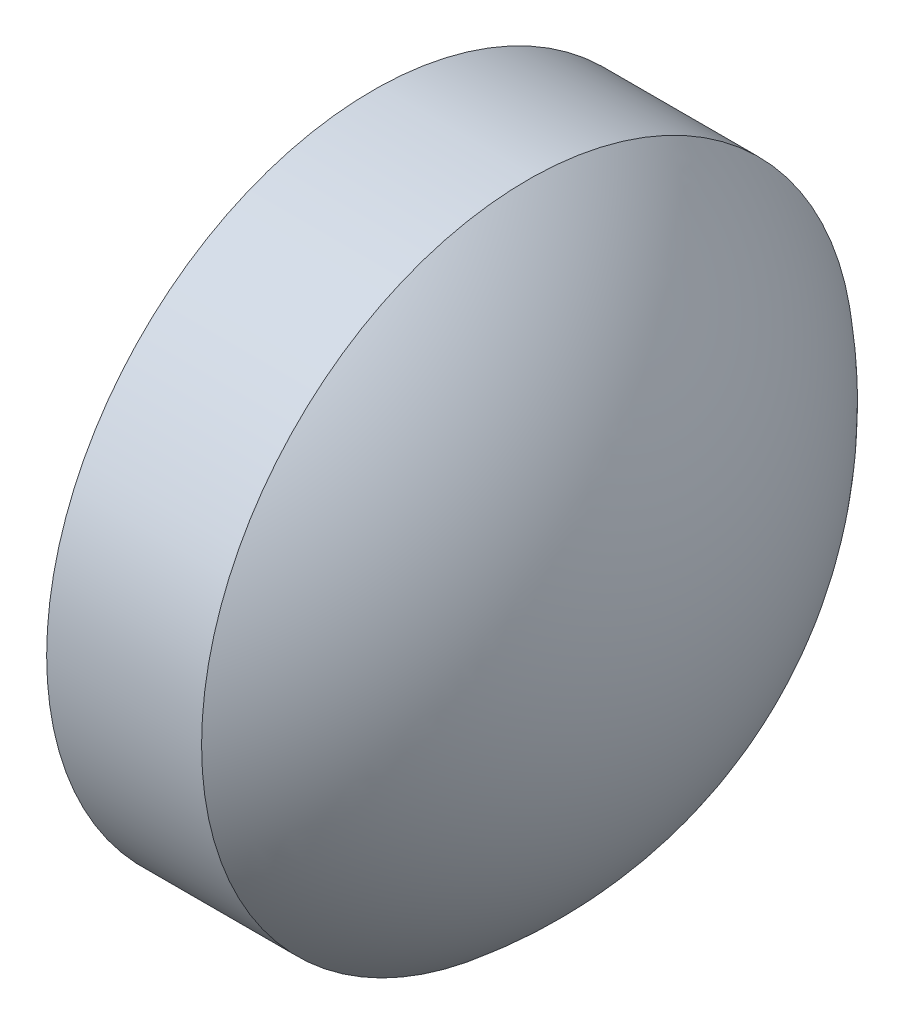
from build123d import *


with BuildPart() as part:
    # 草图1 → 旋转2 (revolve)
    with BuildSketch(Plane.XY, mode=Mode.PRIVATE) as revolve_2_sk:
        with BuildLine():
            Line((385.714763749, -62.775724719), (385.714763749, -60.774375981))
            Line((385.714763749, -60.774375981), (386.664763749, -60.774375981))
            ThreePointArc((386.664763749, -60.774375981), (387.36548352, -61.66790567), (387.614763396, -62.775724719))
            Line((387.614763396, -62.775724719), (385.714763749, -62.775724719))
        make_face()
    revolve(revolve_2_sk.sketch.rotate(Axis((385.31616186, -62.775724719, 0), (1, 0, 0)), 90), axis=Axis((385.31616186, -62.775724719, 0), (1, 0, 0)))  # turned: the seam where the file's is


solid = part.part
